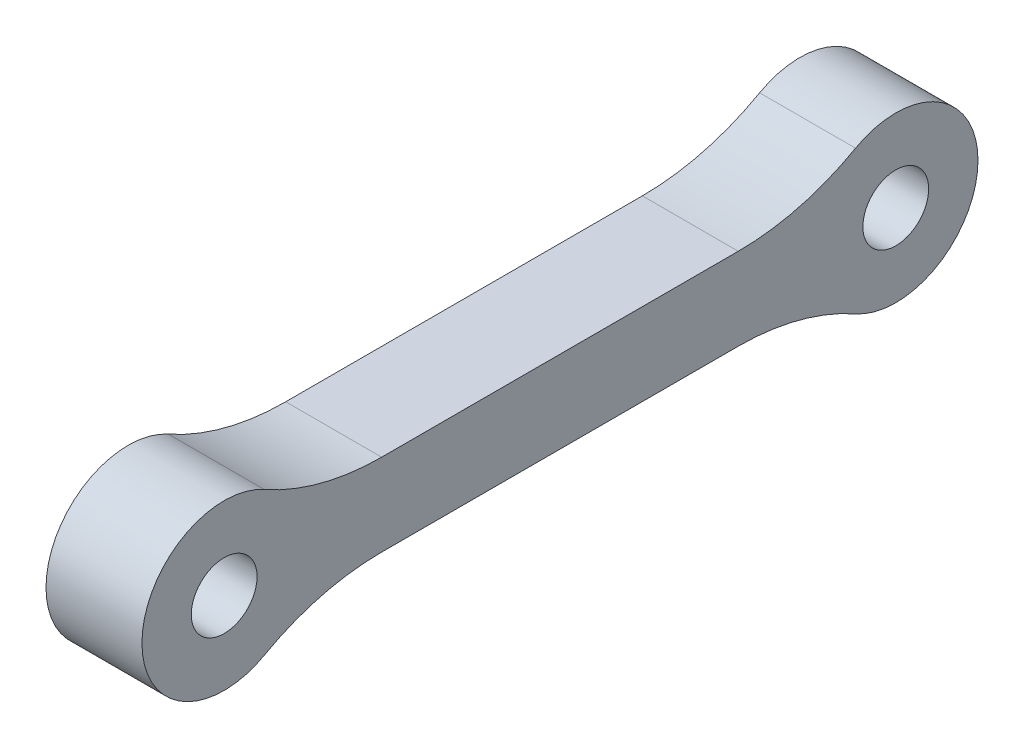
from build123d import *

# Parameters (mm, degrees)
SKETCH1_R           = 1.371428571
BOSS_EXTRUDE1_DEPTH = 4
FILLET1_R           = 10


with BuildPart() as part:
    # Sketch1 → Boss-Extrude1 (new body)
    with BuildSketch(Plane(origin=(0, 0, 0), x_dir=(0, 0, -1), z_dir=(1, 0, 0))):
        with BuildLine():
            Line((18, 1.714285714), (25.030770044, 1.714285714))
            ThreePointArc((25.030770044, 1.714285714), (31.428571429, 0), (25.030770044, -1.714285714))
            Line((25.030770044, -1.714285714), (18, -1.714285714))
            Line((18, -1.714285714), (2.969229956, -1.714285714))
            ThreePointArc((2.969229956, -1.714285714), (-3.428571429, 0), (2.969229956, 1.714285714))
            Line((2.969229956, 1.714285714), (18, 1.714285714))
        make_face()
        Circle(SKETCH1_R, mode=Mode.SUBTRACT)
        with Locations((28, 0)):
            Circle(SKETCH1_R, mode=Mode.SUBTRACT)
    extrude(amount=BOSS_EXTRUDE1_DEPTH)

    # Fillet1
    fillet1_edges = [part.edges().sort_by_distance(p)[0] for p in [
        (2, 1.714285714, -25.030770044),
        (2, -1.714285714, -25.030770044),
        (2, -1.714285714, -2.969229956),
        (2, 1.714285714, -2.969229956),
    ]]
    fillet(fillet1_edges, radius=FILLET1_R)


solid = part.part
